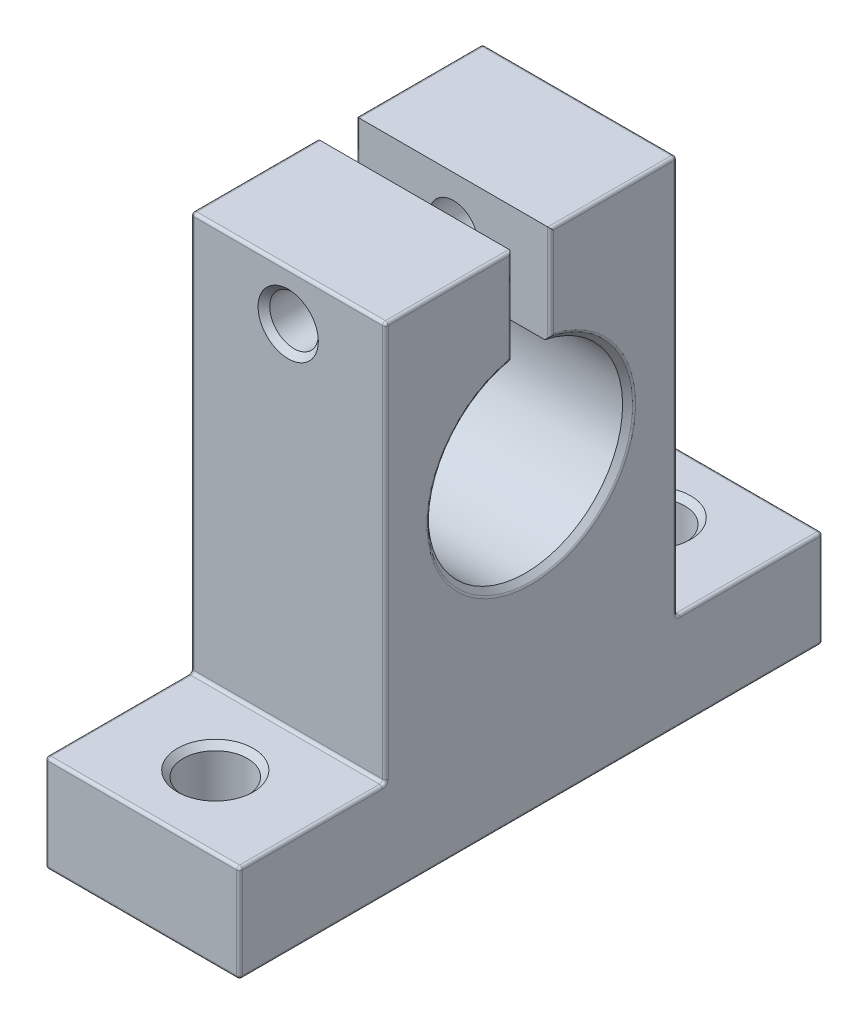
from build123d import *

# Parameters (mm, degrees)
BOSS_EXTRUDE1_DEPTH = 10
SKETCH2_R           = 3.3
CUT_EXTRUDE1_DEPTH  = 11
SKETCH3_R           = 2.5
CUT_EXTRUDE2_DEPTH  = 46
SKETCH4_R           = 4
CUT_EXTRUDE3_DEPTH  = 5
CHAMFER_1_SIZE      = 0.6
FILLET_1_R          = 0.3


with BuildPart() as part:
    # Sketch1 → Boss-Extrude1 (new body, symmetric)
    with BuildSketch(Plane(origin=(0, 0, 0), x_dir=(0, 0, -1), z_dir=(1, 0, 0))):
        with BuildLine():
            Line((-30, 0), (30, 0))
            Line((30, 0), (30, 10))
            Line((30, 10), (15, 10))
            Line((15, 10), (15, 51))
            Line((15, 51), (2, 51))
            Line((2, 51), (2, 40.797958971))
            ThreePointArc((2, 40.797958971), (0, 21), (-2, 40.797958971))
            Line((-2, 40.797958971), (-2, 51))
            Line((-2, 51), (-15, 51))
            Line((-15, 51), (-15, 10))
            Line((-15, 10), (-30, 10))
            Line((-30, 10), (-30, 0))
        make_face()
    extrude(amount=BOSS_EXTRUDE1_DEPTH, both=True)

    # Sketch2 → Cut-Extrude1 (cut, through all)
    with BuildSketch(Plane(origin=(0, 10, 0), x_dir=(1, 0, 0), z_dir=(0, 1, 0))):
        with Locations(Location((0, -22.5, 0), (0, 0, 270))):  # turned: the seam where the file's is
            Circle(SKETCH2_R)
        with Locations(Location((0, 22.5, 0), (0, 0, 270))):  # turned: the seam where the file's is
            Circle(SKETCH2_R)
    extrude(amount=-CUT_EXTRUDE1_DEPTH, mode=Mode.SUBTRACT)

    # Sketch3 → Cut-Extrude2 (cut, through all)
    with BuildSketch(Plane(origin=(0, 0, -15), x_dir=(-1, 0, 0), z_dir=(0, 0, -1))):
        with Locations(Location((0, 46, 0), (0, 0, 90))):  # turned: the seam where the file's is
            Circle(SKETCH3_R)
    extrude(amount=-CUT_EXTRUDE2_DEPTH, mode=Mode.SUBTRACT)

    # Sketch4 → Cut-Extrude3 (cut)
    with BuildSketch(Plane(origin=(0, 0, -15), x_dir=(-1, 0, 0), z_dir=(0, 0, -1))):
        with Locations((0, 46)):
            Circle(SKETCH4_R)
    extrude(amount=-CUT_EXTRUDE3_DEPTH, mode=Mode.SUBTRACT)

    # Фаска1
    chamfer_1_edges = [part.edges().sort_by_distance(p)[0] for p in [
        (10, 21, 0),
        (0, 0, 19.2),
        (0, 10, 19.2),
        (0, 0, -25.8),
        (0, 10, -25.8),
        (0, 43.5, 15),
        (4, 46, -15),
    ]]
    chamfer(chamfer_1_edges, length=CHAMFER_1_SIZE)

    # Скругление1
    fillet_1_edges = [part.edges().sort_by_distance(p)[0] for p in [
        (-10, 0, 0),
        (-10, 5, -30),
        (-10, 10, -22.5),
        (-10, 30.5, -15),
        (-10, 51, -8.5),
        (-10, 45.898979486, -2),
        (-10, 21, 0),
        (-10, 45.898979486, 2),
        (-10, 51, 8.5),
        (-10, 30.5, 15),
        (-10, 10, 22.5),
        (-10, 5, 30),
        (10, 51, -8.5),
        (10, 30.5, -15),
        (10, 10, -22.5),
        (10, 5, -30),
        (10, 0, 0),
        (10, 5, 30),
        (10, 10, 22.5),
        (10, 30.5, 15),
        (10, 51, 8.5),
        (10, 46.204805472, 2),
        (10, 20.4, 0),
        (10, 46.204805472, -2),
        (0, 0, -30),
        (0, 10, -30),
        (0, 10, -15),
        (0, 51, -15),
        (0, 0, 30),
        (0, 10, 30),
        (0, 10, 15),
        (0, 51, 15),
    ]]
    fillet(fillet_1_edges, radius=FILLET_1_R)


solid = part.part
